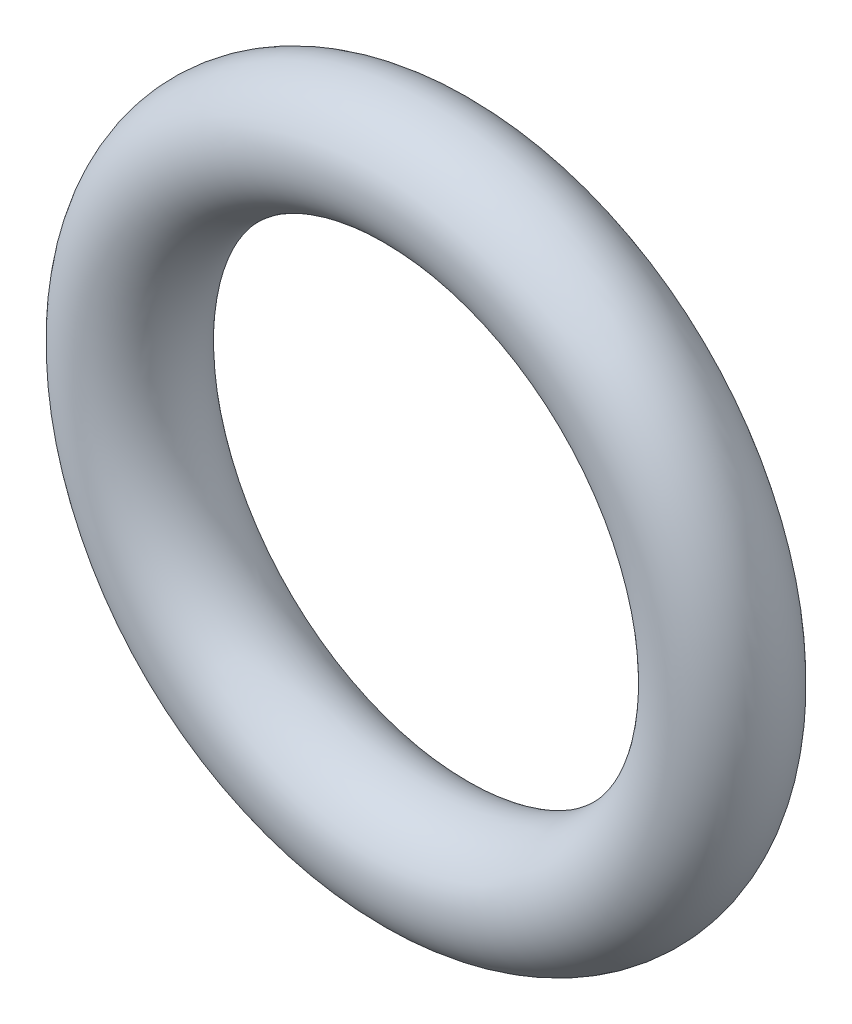
from build123d import *

# Parameters (mm, degrees)
SKETCH1_R = 1.68671875


with BuildPart() as part:
    # Sweep1: sweep along a path in Sketch2
    with BuildLine(Plane.XY) as sweep1_path:
        CenterArc((0, -8.43359375), 8.43359375, 0, 360)
    # Sketch1 → Sweep1 (sweep)
    with BuildSketch(Plane(origin=(0, 0, 0), x_dir=(0, 0, -1), z_dir=(1, 0, 0))):
        Circle(SKETCH1_R)
    sweep(path=sweep1_path.line)


solid = part.part
